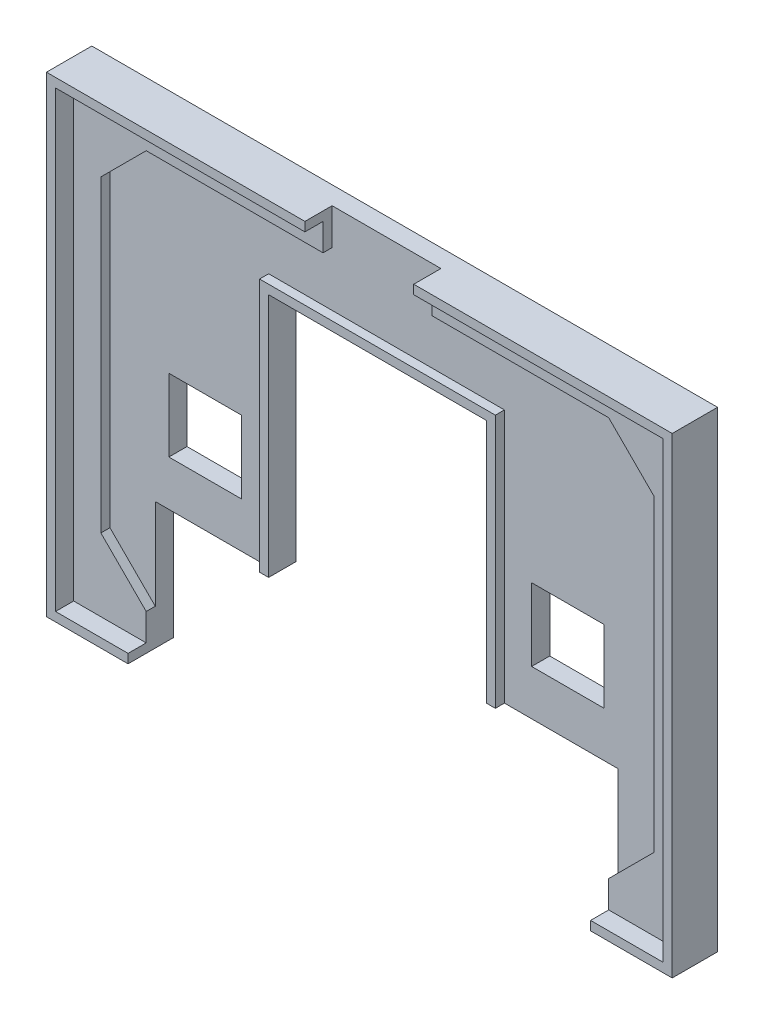
from build123d import *

# Parameters (mm, degrees)
SKICA1_W                    = 67
SKICA1_H                    = 50
P_IDAT_VYSUNUT_M1_DEPTH     = 3
ODEBRAT_VYSUNUT_M1_DEPTH    = 1
SKICA3_W                    = 8
SKICA3_H                    = 8
ODEBRAT_VYSUNUT_M2_DEPTH    = 4
VYSUNOUT_TENKOST_NN_1_DEPTH = 1
VYSUNOUT_TENKOST_NN_2_DEPTH = 5
SKICA6_W                    = 12
SKICA6_H                    = 4
ODEBRAT_VYSUNUT_M3_DEPTH    = 4
ODEBRAT_VYSUNUT_M5_DEPTH    = 1
P_IDAT_START                = -1
P_IDAT_VYSUNUT_M3_DEPTH     = 1
ODEBRAT_VYSUNUT_M6_DEPTH    = 1
SKICA10_W                   = 1.6
SKICA10_H                   = 2.4
P_IDAT_VYSUNUT_M4_DEPTH     = 1


with BuildPart() as part:
    # Skica1 → Přidat vysunutím1 (new body)
    with BuildSketch(Plane.XY):
        Rectangle(SKICA1_W, SKICA1_H)
    extrude(amount=P_IDAT_VYSUNUT_M1_DEPTH)

    # Skica2 → Odebrat vysunutím1 (cut)
    with BuildSketch(Plane.XY.offset(3)):
        Polygon((-25.5, -22), (-30.5, -17), (-30.5, 17), (-25.5, 22), (25.5, 22), (30.5, 17), (30.5, -17), (25.5, -22), align=None)
    extrude(amount=-ODEBRAT_VYSUNUT_M1_DEPTH, mode=Mode.SUBTRACT)

    # Skica3 → Odebrat vysunutím2 (cut, through all)
    with BuildSketch(Plane(origin=(0, 0, 0), x_dir=(-1, 0, 0), z_dir=(0, 0, -1))):
        with Locations((20, -3)):
            Rectangle(SKICA3_W, SKICA3_H)
        with Locations((-20, -3)):
            Rectangle(SKICA3_W, SKICA3_H)
        Polygon((25.5, -25), (-25.5, -25), (-25.5, -12), (-12, -12), (-12, 15), (12, 15), (12, -12), (25.5, -12), align=None)
    extrude(amount=-ODEBRAT_VYSUNUT_M2_DEPTH, mode=Mode.SUBTRACT)

    # Skica4 → Vysunout tenkostěnný1 (add)
    with BuildSketch(Plane.XY.offset(2)):
        Polygon((-12, -12), (-12, 15), (12, 15), (12, -12), (13, -12), (13, 16), (-13, 16), (-13, -12), align=None)
    extrude(amount=VYSUNOUT_TENKOST_NN_1_DEPTH)

    # Skica5 → Vysunout tenkostěnný2 (add)
    with BuildSketch(Plane(origin=(0, 0, 0), x_dir=(-1, 0, 0), z_dir=(0, 0, -1))):
        Polygon((-25.5, -25), (-33.5, -25), (-33.5, 25), (33.5, 25), (33.5, -25), (25.5, -25), (25.5, -26), (34.5, -26), (34.5, 26), (-34.5, 26), (-34.5, -26), (-25.5, -26), align=None)
    extrude(amount=-VYSUNOUT_TENKOST_NN_2_DEPTH)

    # Skica6 → Odebrat vysunutím3 (cut, through all)
    with BuildSketch(Plane.XY.offset(2)):
        with Locations((0, 24)):
            Rectangle(SKICA6_W, SKICA6_H)
    extrude(amount=ODEBRAT_VYSUNUT_M3_DEPTH, mode=Mode.SUBTRACT)

    # Skica7 → Odebrat vysunutím5 (cut)
    with BuildSketch(Plane(origin=(0, 0, 0), x_dir=(-1, 0, 0), z_dir=(0, 0, -1))):
        Polygon((-32.44, 14.540476732), (-23.459523268, 23.94), (-14.06, 14.959523268), (-23.040476732, 5.56), align=None)
        Polygon((14.06, 14.959523268), (23.040476732, 5.56), (32.44, 14.540476732), (23.459523268, 23.94), align=None)
    extrude(amount=-ODEBRAT_VYSUNUT_M5_DEPTH, mode=Mode.SUBTRACT)

    # Skica8 → Přidat vysunutím3 (add)
    with BuildSketch(Plane(origin=(0, 0, 0), x_dir=(-1, 0, 0), z_dir=(0, 0, -1)).offset(P_IDAT_START)):
        Polygon((-29.266904741, 14.966465555), (-27.459304113, 13.239450799), (-25.766904741, 15.010820822), align=None)
        Polygon((-23.626799477, 17.250787567), (-21.932856893, 19.023772811), (-23.740457522, 20.750787567), align=None)
        Polygon((-24.551025932, 9.769304113), (-26.358626561, 11.496318869), (-25.667820659, 12.21935912), (-23.940805902, 12.21935912), (-23.940805902, 14.026959749), (-22.559194098, 15.473040251), (-20.832179341, 15.473040251), (-20.832179341, 17.28064088), (-20.141373439, 18.003681131), (-18.333772811, 16.276666375), (-20.751593469, 13.746025495), (-22.304085189, 13.84625566), (-22.133205274, 12.299944993), align=None)
        Polygon((27.459304113, 13.239450799), (25.766904741, 15.010820822), (29.266904741, 14.966465555), align=None)
        Polygon((23.626799477, 17.250787567), (21.932856893, 19.023772811), (23.740457522, 20.750787567), align=None)
        Polygon((23.940805902, 14.026959749), (22.559194098, 15.473040251), (20.832179341, 15.473040251), (20.832179341, 17.28064088), (20.141373439, 18.003681131), (18.333772811, 16.276666375), (20.751593469, 13.746025495), (22.304085189, 13.84625566), (22.133205274, 12.299944993), (24.551025932, 9.769304113), (26.358626561, 11.496318869), (25.667820659, 12.21935912), (23.940805902, 12.21935912), align=None)
    extrude(amount=P_IDAT_VYSUNUT_M3_DEPTH)

    # Skica9 → Odebrat vysunutím6 (cut)
    with BuildSketch(Plane(origin=(0, 0, 0), x_dir=(-1, 0, 0), z_dir=(0, 0, -1))):
        Polygon((-10.3, 23.3), (-7.1, 23.3), (-7.1, 22.5), (-6.3, 22.5), (-6.3, 21.7), (-7.9, 21.7), (-7.9, 22.5), (-9.5, 22.5), (-9.5, 18.5), (-7.9, 18.5), (-7.9, 19.3), (-8.7, 19.3), (-8.7, 20.1), (-6.3, 20.1), (-6.3, 18.5), (-7.1, 18.5), (-7.1, 17.7), (-10.3, 17.7), (-10.3, 18.5), (-11.1, 18.5), (-11.1, 22.5), (-10.3, 22.5), align=None)
        Polygon((-5.3, 23.3), (-1.3, 23.3), (-1.3, 22.3), (-4, 22.3), (-4, 21), (-2.4, 21), (-2.4, 20), (-4, 20), (-4, 18.7), (-1.3, 18.7), (-1.3, 17.7), (-5.3, 17.7), align=None)
        Polygon((-0.3, 23.3), (1.3, 23.3), (1.3, 22.5), (2.1, 22.5), (2.1, 21.7), (2.9, 21.7), (2.9, 22.5), (3.7, 22.5), (3.7, 23.3), (5.3, 23.3), (5.3, 17.7), (3.7, 17.7), (3.7, 20.7), (2.9, 20.7), (2.9, 19.9), (2.1, 19.9), (2.1, 20.7), (1.3, 20.7), (1.3, 17.7), (-0.3, 17.7), align=None)
        Polygon((7.1, 23.3), (10.3, 23.3), (10.3, 22.5), (11.1, 22.5), (11.1, 18.5), (10.3, 18.5), (10.3, 17.7), (7.1, 17.7), (7.1, 18.5), (6.3, 18.5), (6.3, 22.5), (7.1, 22.5), align=None)
    extrude(amount=-ODEBRAT_VYSUNUT_M6_DEPTH, mode=Mode.SUBTRACT)

    # Skica10 → Přidat vysunutím4 (add)
    with BuildSketch(Plane(origin=(0, 0, 1), x_dir=(-1, 0, 0), z_dir=(0, 0, -1))):
        with Locations((8.7, 20.5)):
            Rectangle(SKICA10_W, SKICA10_H)
    extrude(amount=P_IDAT_VYSUNUT_M4_DEPTH)


solid = part.part
